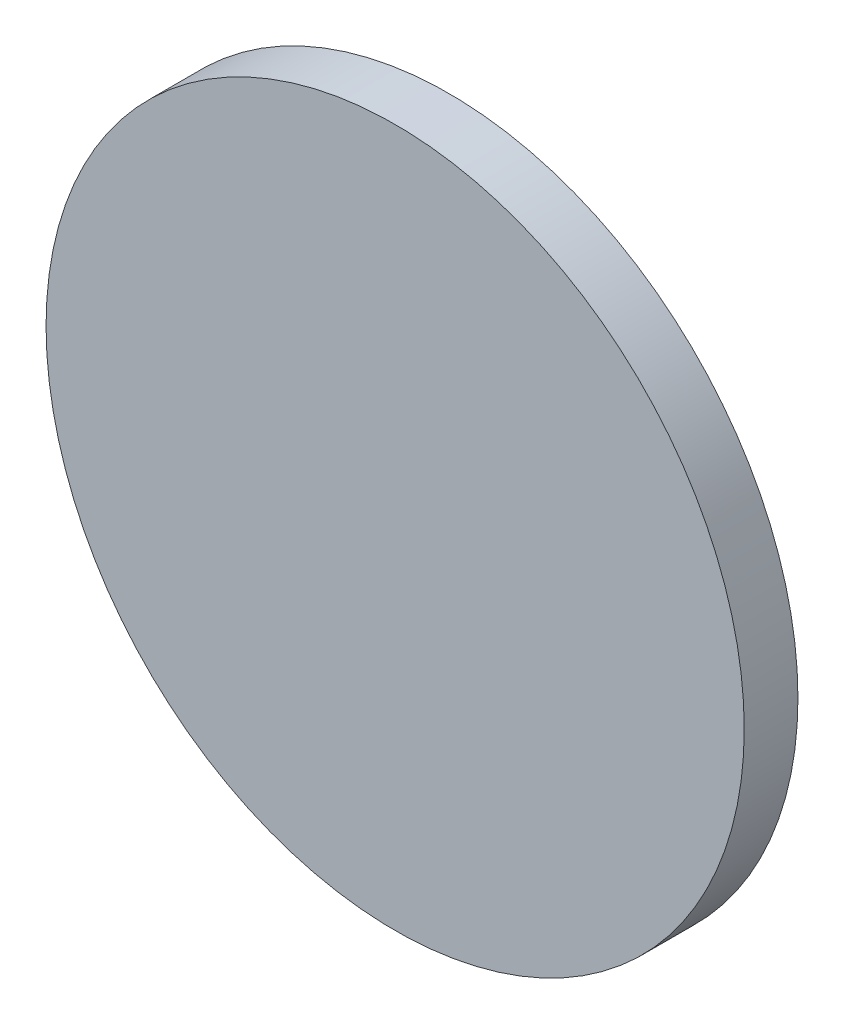
from build123d import *

# Parameters (mm, degrees)
SKETCH3_R           = 330.2
BOSS_EXTRUDE2_DEPTH = 50.8


with BuildPart() as part:
    # Sketch3 → Boss-Extrude2 (new body)
    with BuildSketch(Plane.XY):
        Circle(SKETCH3_R)
    extrude(amount=BOSS_EXTRUDE2_DEPTH)


solid = part.part
